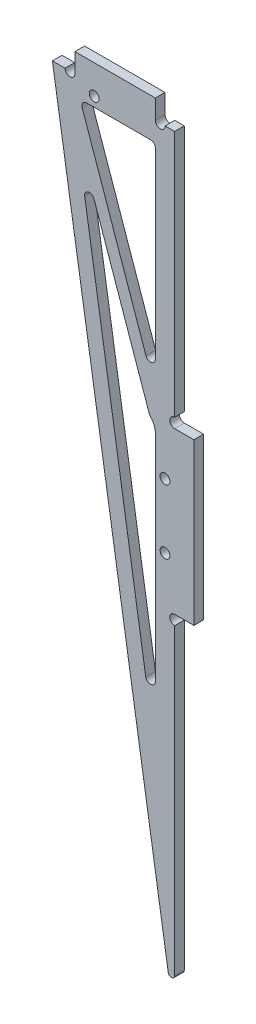
from build123d import *

# Parameters (mm, degrees)
EXTRUDE_1_DEPTH     = 3
SKETCH_2_R          = 1.525
CUT_EXTRUDE_1_DEPTH = 40
SKETCH_4_W          = 25
SKETCH_4_H          = 6
SKETCH_4_W_2        = 6
SKETCH_4_H_2        = 50
EXTRUDE_2_DEPTH     = 3
SKETCH_5_R          = 1.525
CUT_EXTRUDE_2_DEPTH = 40
CUT_EXTRUDE_3_DEPTH = 60
FILLET_1_R          = 1
FILLET_2_R          = 1.5
EXTRUDE_3_DEPTH     = 3
FILLET_3_R          = 5
FILLET_4_R          = 1.5


with BuildPart() as part:
    # 草图1 → 凸台-拉伸1 (new body)
    with BuildSketch(Plane.XY):
        Polygon((-38, 0), (0, 0), (0, -240), align=None)
    extrude(amount=EXTRUDE_1_DEPTH)

    # 草图2 → 切除-拉伸1 (cut)
    with BuildSketch(Plane.XY.offset(3)):
        with Locations((-3, -115)):
            Circle(SKETCH_2_R)
        with Locations((-3, -95)):
            Circle(SKETCH_2_R)
        with Locations((-25, -3)):
            Circle(SKETCH_2_R)
    extrude(amount=-CUT_EXTRUDE_1_DEPTH, mode=Mode.SUBTRACT)

    # 草图4 → 凸台-拉伸2 (add)
    with BuildSketch(Plane.XY.offset(3)):
        with Locations((-18.5, 3)):
            Rectangle(SKETCH_4_W, SKETCH_4_H)
        with Locations((3, -105)):
            Rectangle(SKETCH_4_W_2, SKETCH_4_H_2)
    extrude(amount=-EXTRUDE_2_DEPTH)

    # 草图5 → 切除-拉伸2 (cut)
    with BuildSketch(Plane(origin=(0, 0, 0), x_dir=(-1, 0, 0), z_dir=(0, 0, -1))):
        with Locations((0, -78.475)):
            Circle(SKETCH_5_R)
        with Locations((0, -131.525)):
            Circle(SKETCH_5_R)
        with Locations((4.475, 0)):
            Circle(SKETCH_5_R)
        with Locations((32.525, 0)):
            Circle(SKETCH_5_R)
    extrude(amount=-CUT_EXTRUDE_2_DEPTH, mode=Mode.SUBTRACT)

    # 草图6 → 切除-拉伸3 (cut)
    with BuildSketch(Plane(origin=(0, 0, 0), x_dir=(-1, 0, 0), z_dir=(0, 0, -1))):
        Polygon((6, -6), (6, -170.132932669), (31.987714339, -6), align=None)
    extrude(amount=-CUT_EXTRUDE_3_DEPTH, mode=Mode.SUBTRACT)

    # 圆角1
    fillet_1_edges = [part.edges().sort_by_distance(p)[0] for p in [
        (0, -240, 1.5),
    ]]
    fillet(fillet_1_edges, radius=FILLET_1_R)

    # 圆角2
    fillet_2_edges = [part.edges().sort_by_distance(p)[0] for p in [
        (-6, -6, 1.5),
        (-31.987714339, -6, 1.5),
        (-6, -170.132932669, 1.5),
    ]]
    fillet(fillet_2_edges, radius=FILLET_2_R)

    # 草图7 → 凸台-拉伸3 (add)
    with BuildSketch(Plane(origin=(0, 0, 0), x_dir=(-1, 0, 0), z_dir=(0, 0, -1))):
        with BuildLine():
            Line((7.888469575, -79.942320526), (33.26058288, -7.184345364))
            ThreePointArc((33.26058288, -7.184345364), (32.030659174, -4.637329919), (29.483643729, -5.867253624))
            Line((29.483643729, -5.867253624), (4.111530425, -78.625228786))
            ThreePointArc((4.111530425, -78.625228786), (5.34145413, -81.172244231), (7.888469575, -79.942320526))
        make_face()
    extrude(amount=-EXTRUDE_3_DEPTH)

    # 圆角3
    fillet_3_edges = [part.edges().sort_by_distance(p)[0] for p in [
        (-6, -81.283774656, 1.5),
    ]]
    fillet(fillet_3_edges, radius=FILLET_3_R)

    # 圆角4
    fillet_4_edges = [part.edges().sort_by_distance(p)[0] for p in [
        (-6, -73.209786217, 1.5),
        (-30.585668879, -14.855023959, 1.5),
        (-29.4373525, -6, 1.5),
    ]]
    fillet(fillet_4_edges, radius=FILLET_4_R)


solid = part.part
